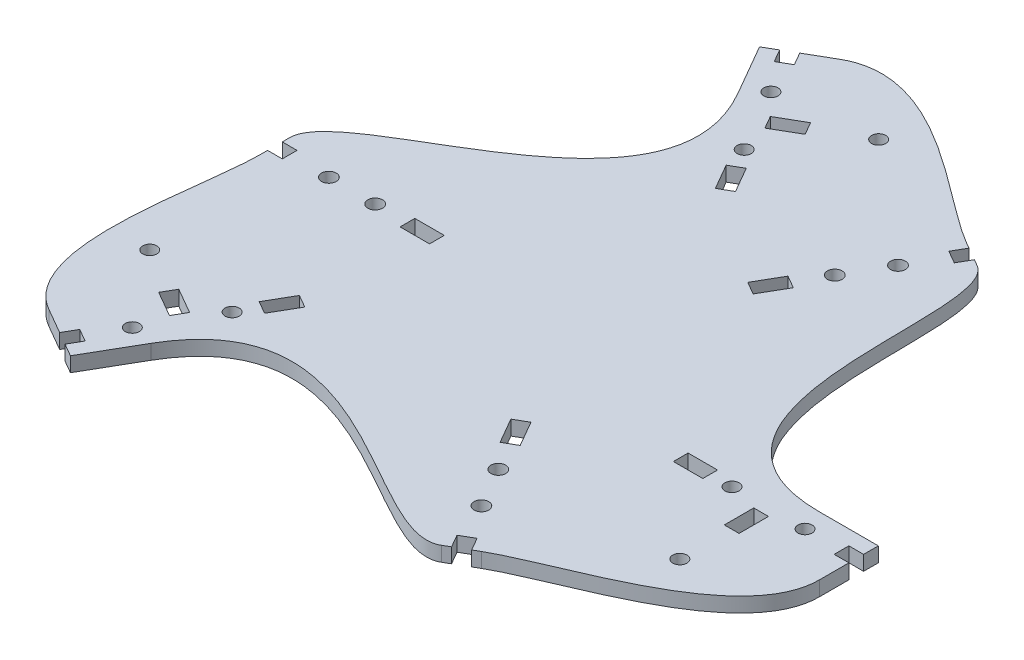
from build123d import *

# Parameters (mm, degrees)
SKETCH1_R           = 1.524
SKETCH1_R_2         = 1.587500001
SKETCH1_R_3         = 1.5875
SKETCH1_R_4         = 1.523999993
SKETCH1_R_5         = 1.523999992
SKETCH1_R_6         = 1.587499996
SKETCH1_R_7         = 1.523999994
SKETCH1_R_8         = 1.587499994
SKETCH1_W           = 6.35
SKETCH1_H           = 3.175
SKETCH1_W_2         = 3.175
SKETCH1_H_2         = 6.35
BOSS_EXTRUDE1_DEPTH = 3.175


with BuildPart() as part:
    # Sketch1 → Boss-Extrude1 (new body)
    with BuildSketch(Plane(origin=(0, 0, 0), x_dir=(1, 0, 0), z_dir=(0, 1, 0))):
        with BuildLine():
            Line((-46.403884523, -61.196885763), (-49.15351518, -59.609385763))
            Line((-49.15351518, -59.609385763), (-47.56601518, -56.859755106))
            Line((-47.56601518, -56.859755106), (-50.315645837, -55.272255106))
            Line((-50.315645837, -55.272255106), (-51.903145837, -58.021885763))
            Line((-51.903145837, -58.021885763), (-57.402407151, -54.846885763))
            add(Edge.make_bspline(
                [(-63.499999964, -3.175000051), (-63.499999964, -15.74075082), (-71.94938611, -46.448183545), (-57.402407151, -54.846885763)],
                knots=[0, 0, 0, 0, 1, 1, 1, 1], degree=3))
            Line((-63.499999964, -3.175000051), (-63.499999964, -1.587500051))
            Line((-63.499999964, -1.587500051), (-60.324999964, -1.587500051))
            Line((-60.324999964, -1.587500051), (-60.324999964, 1.587499949))
            Line((-60.324999964, 1.587499949), (-63.499999964, 1.587499949))
            Line((-63.499999964, 1.587499949), (-63.499999964, 3.174999949))
            add(Edge.make_bspline(
                [(-23.44611538, 59.78686309), (-4.72729916, 27.364922338), (-63.499999964, 16.015994216), (-63.499999964, 3.174999949)],
                knots=[0, 0, 0, 0, 1, 1, 1, 1], degree=3))
            Line((-23.44611538, 59.78686309), (-29.79611538, 70.785385718))
            Line((-29.79611538, 70.785385718), (-27.046484723, 72.372885718))
            Line((-27.046484723, 72.372885718), (-25.458984723, 69.623255061))
            Line((-25.458984723, 69.623255061), (-22.709354066, 71.210755061))
            Line((-22.709354066, 71.210755061), (-24.296854066, 73.960385718))
            Line((-24.296854066, 73.960385718), (-18.797592752, 77.135385718))
            add(Edge.make_bspline(
                [(29.000369343, 56.58011314), (18.118109959, 62.862988525), (-4.250613793, 85.534087936), (-18.797592752, 77.135385718)],
                knots=[0, 0, 0, 0, 1, 1, 1, 1], degree=3))
            Line((29.000369343, 56.58011314), (30.375184671, 55.786363141))
            Line((30.375184671, 55.786363141), (28.787684671, 53.036732484))
            Line((28.787684671, 53.036732484), (31.537315328, 51.449232484))
            Line((31.537315328, 51.449232484), (33.124815328, 54.198863141))
            Line((33.124815328, 54.198863141), (34.499630657, 53.405113141))
            add(Edge.make_bspline(
                [(63.5, -9.5885), (26.062367559, -9.5885), (45.620257902, 46.984616007), (34.499630657, 53.405113141)],
                knots=[0, 0, 0, 0, 1, 1, 1, 1], degree=3))
            Line((63.5, -9.5885), (76.2, -9.5885))
            Line((76.2, -9.5885), (76.2, -12.7635))
            Line((76.2, -12.7635), (73.025, -12.7635))
            Line((73.025, -12.7635), (73.025, -15.9385))
            Line((73.025, -15.9385), (76.2, -15.9385))
            Line((76.2, -15.9385), (76.2, -22.2885))
            add(Edge.make_bspline(
                [(34.499630719, -53.405113134), (45.381890103, -47.122237749), (76.2, -39.085904436), (76.2, -22.2885)],
                knots=[0, 0, 0, 0, 1, 1, 1, 1], degree=3))
            Line((34.499630719, -53.405113134), (33.12481539, -54.198863134))
            Line((33.12481539, -54.198863134), (31.53731539, -51.449232477))
            Line((31.53731539, -51.449232477), (28.787684733, -53.036732477))
            Line((28.787684733, -53.036732477), (30.375184734, -55.786363134))
            Line((30.375184734, -55.786363134), (29.000369405, -56.580113134))
            add(Edge.make_bspline(
                [(-40.053884523, -50.198363135), (-21.335068302, -17.776422383), (17.87974216, -63.000610268), (29.000369405, -56.580113134)],
                knots=[0, 0, 0, 0, 1, 1, 1, 1], degree=3))
            Line((-40.053884523, -50.198363135), (-46.403884523, -61.196885763))
        make_face()
        with Locations((65.151, -14.351)):
            Circle(SKETCH1_R, mode=Mode.SUBTRACT)
        with Locations((49.403, -14.351)):
            Circle(SKETCH1_R, mode=Mode.SUBTRACT)
        with Locations((25.933399999, 44.917966413)):
            Circle(SKETCH1_R_2, mode=Mode.SUBTRACT)
        with Locations((20.9423, 36.273127627)):
            Circle(SKETCH1_R_3, mode=Mode.SUBTRACT)
        with Locations((-45.003830508, -49.246921076)):
            Circle(SKETCH1_R_4, mode=Mode.SUBTRACT)
        with Locations((-37.129830508, -35.608753018)):
            Circle(SKETCH1_R_5, mode=Mode.SUBTRACT)
        with Locations((25.933400062, -44.917966407)):
            Circle(SKETCH1_R_6, mode=Mode.SUBTRACT)
        with Locations((20.942300062, -36.273127622)):
            Circle(SKETCH1_R_3, mode=Mode.SUBTRACT)
        with Locations((-20.147169395, 63.597921031)):
            Circle(SKETCH1_R_7, mode=Mode.SUBTRACT)
        with Locations((-12.273169395, 49.959752973)):
            Circle(SKETCH1_R_4, mode=Mode.SUBTRACT)
        with Locations((-51.866799964, -5.1e-08)):
            Circle(SKETCH1_R_8, mode=Mode.SUBTRACT)
        with Locations((-41.884599964, -5.1e-08)):
            Circle(SKETCH1_R_3, mode=Mode.SUBTRACT)
        with Locations((57.277, -33.4645)):
            Circle(SKETCH1_R, mode=Mode.SUBTRACT)
        with Locations((-57.619607125, -32.871087053)):
            Circle(SKETCH1_R, mode=Mode.SUBTRACT)
        with Locations((0.342607125, 66.335587053)):
            Circle(SKETCH1_R, mode=Mode.SUBTRACT)
        Polygon((15.662315328, 23.952925913), (18.837315328, 29.452187227), (16.087684671, 31.039687227), (12.912684671, 25.540425913), align=None, mode=Mode.SUBTRACT)
        Polygon((-41.647895898, -40.259271724), (-43.235395898, -43.008902381), (-48.734657212, -39.833902381), (-47.147157212, -37.084271724), align=None, mode=Mode.SUBTRACT)
        with Locations((41.529, -14.351)):
            Rectangle(SKETCH1_W, SKETCH1_H, mode=Mode.SUBTRACT)
        Polygon((12.912684733, -25.540425908), (16.087684733, -31.039687222), (18.83731539, -29.452187222), (15.66231539, -23.952925908), align=None, mode=Mode.SUBTRACT)
        Polygon((-30.23051518, -26.833788331), (-33.40551518, -32.333049645), (-36.155145837, -30.745549645), (-32.980145837, -25.246288331), align=None, mode=Mode.SUBTRACT)
        with Locations((-31.749999964, -5e-08)):
            Rectangle(SKETCH1_W, SKETCH1_H, mode=Mode.SUBTRACT)
        Polygon((-8.123484723, 39.597288286), (-11.298484723, 45.0965496), (-8.548854066, 46.6840496), (-5.373854066, 41.184788286), align=None, mode=Mode.SUBTRACT)
        with Locations((57.277, -19.1135)):
            Rectangle(SKETCH1_W_2, SKETCH1_H_2, mode=Mode.SUBTRACT)
        Polygon((-14.041604102, 56.197771724), (-15.629104102, 58.947402381), (-10.129842788, 62.122402381), (-8.542342788, 59.372771724), align=None, mode=Mode.SUBTRACT)
    extrude(amount=BOSS_EXTRUDE1_DEPTH)


solid = part.part
